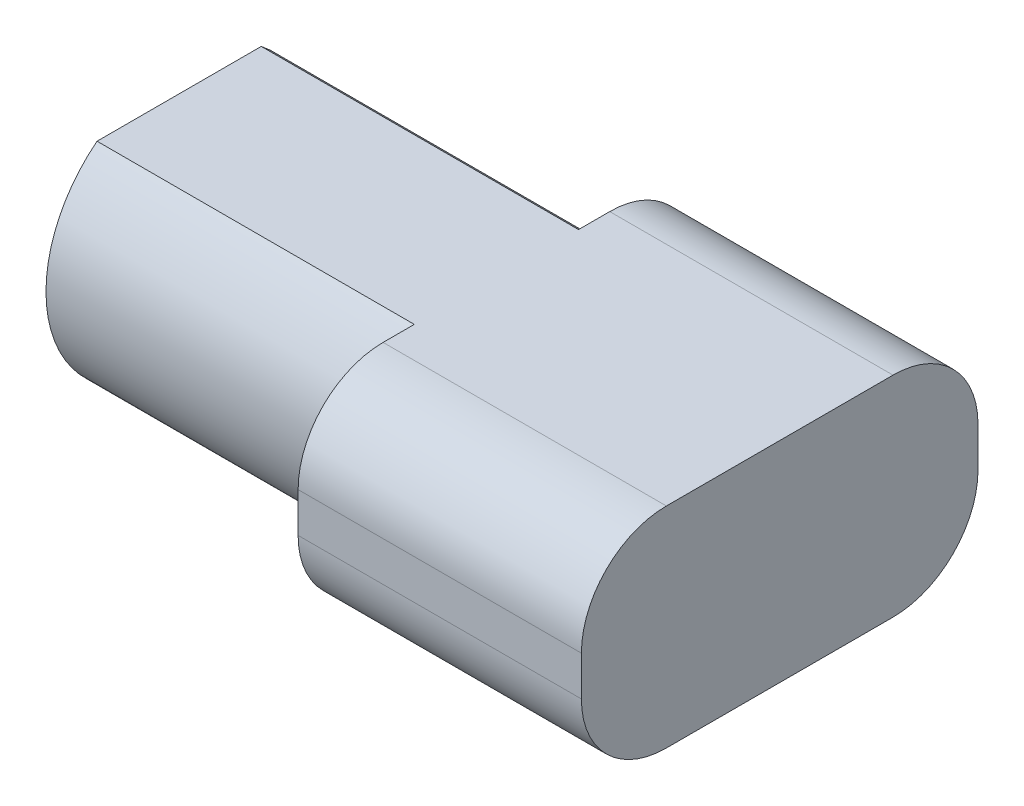
from build123d import *

# Parameters (mm, degrees)
BOSS_EXTRUDE1_DEPTH = 5.6
BOSS_EXTRUDE2_DEPTH = 5
FILLET1_R           = 1.5


with BuildPart() as part:
    # Sketch1 → Boss-Extrude1 (new body)
    with BuildSketch(Plane(origin=(0, 0, 0), x_dir=(0, 0, -1), z_dir=(1, 0, 0))):
        with BuildLine():
            Line((-1.449137675, 1.85), (1.449137675, 1.85))
            ThreePointArc((1.449137675, 1.85), (2.35, 0), (1.449137675, -1.85))
            Line((1.449137675, -1.85), (-1.449137675, -1.85))
            ThreePointArc((-1.449137675, -1.85), (-2.35, 0), (-1.449137675, 1.85))
        make_face()
    extrude(amount=BOSS_EXTRUDE1_DEPTH)

    # Sketch2 → Boss-Extrude2 (add)
    with BuildSketch(Plane(origin=(5.6, 0, 0), x_dir=(0, 0, -1), z_dir=(1, 0, 0))):
        Polygon((0, 1.85), (-3.5, 1.85), (-3.5, -1.85), (-1.449137675, -1.85), (1.449137675, -1.85), (3.5, -1.85), (3.5, 1.85), align=None)
    extrude(amount=BOSS_EXTRUDE2_DEPTH)

    # Fillet1
    fillet1_edges = [part.edges().sort_by_distance(p)[0] for p in [
        (8.1, -1.85, -3.5),
        (8.1, 1.85, -3.5),
        (8.1, -1.85, 3.5),
        (8.1, 1.85, 3.5),
    ]]
    fillet(fillet1_edges, radius=FILLET1_R)


solid = part.part
